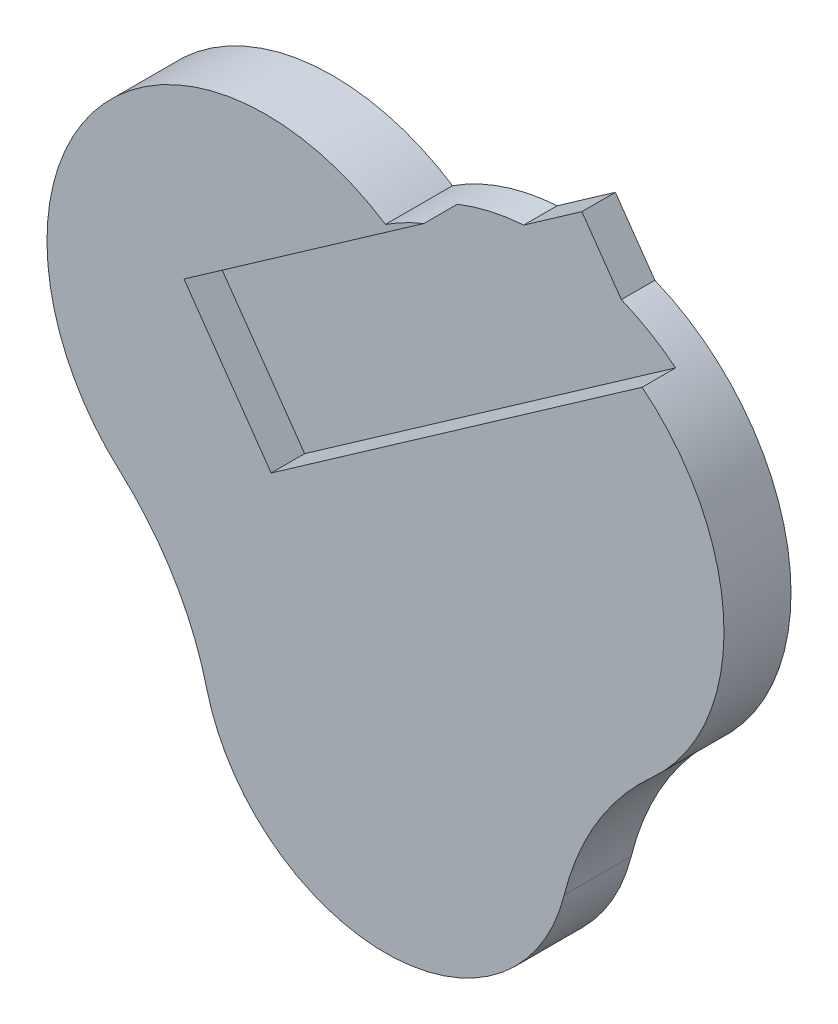
from build123d import *

# Parameters (mm, degrees)
BOSS_EXTRUDE1_DEPTH = 38.1
BOSS_EXTRUDE2_DEPTH = 19.05
BOSS_EXTRUDE3_DEPTH = 19.05


with BuildPart() as part:
    # Sketch2 → Boss-Extrude1 (new body)
    with BuildSketch(Plane.XY):
        with BuildLine():
            Line((0, 159.7945402), (24.767030522, 124.423554927))
            Line((24.767030522, 124.423554927), (235.653251342, 272.08767645))
            ThreePointArc((235.653251342, 272.08767645), (282.133094114, 178.538387025), (240.963304039, 82.533732339))
            ThreePointArc((240.963304039, 82.533732339), (209.988023007, 44.978276319), (191.364517126, 0))
            ThreePointArc((191.364517126, 0), (89.764517126, -79.406163555), (-11.835482874, 0))
            ThreePointArc((-11.835482874, 0), (-30.458988755, 44.978276319), (-61.434269787, 82.533732339))
            ThreePointArc((-61.434269787, 82.533732339), (-76.883813046, 250.879864381), (89.764517126, 279.295399058))
            ThreePointArc((89.764517126, 279.295399058), (100.369013371, 285.48693454), (111.532091006, 290.603197817))
            Line((111.532091006, 290.603197817), (-24.767030522, 195.165525472))
            Line((-24.767030522, 195.165525472), (0, 159.7945402))
        make_face()
    extrude(amount=BOSS_EXTRUDE1_DEPTH)



with BuildPart() as body_2:
    # Sketch3 → Boss-Extrude2 (new body)
    with BuildSketch(Plane(origin=(0, 0, 0), x_dir=(-1, 0, 0), z_dir=(0, 0, -1))):
        with BuildLine():
            Line((24.767030522, 195.165525472), (-24.767030522, 124.423554927))
            Line((-24.767030522, 124.423554927), (-235.653251342, 272.08767645))
            ThreePointArc((-235.653251342, 272.08767645), (-176.097486655, 298.136787359), (-111.532091006, 290.603197817))
            Line((-111.532091006, 290.603197817), (24.767030522, 195.165525472))
        make_face()
    extrude(amount=-BOSS_EXTRUDE2_DEPTH)


with BuildPart() as part_1:
    add(part.part)

    add(body_2.part)  # Boss-Extrude3 merges body 2
    # Sketch4 → Boss-Extrude3 (add)
    with BuildSketch(Plane(origin=(0, 0, 0), x_dir=(-1, 0, 0), z_dir=(0, 0, -1))):
        Polygon((-152.689068197, 231.824942879), (-215.108453971, 275.531467329), (-182.328560634, 322.34600666), (-119.909174859, 278.63948221), align=None)
    extrude(amount=-BOSS_EXTRUDE3_DEPTH)


solid = part_1.part
